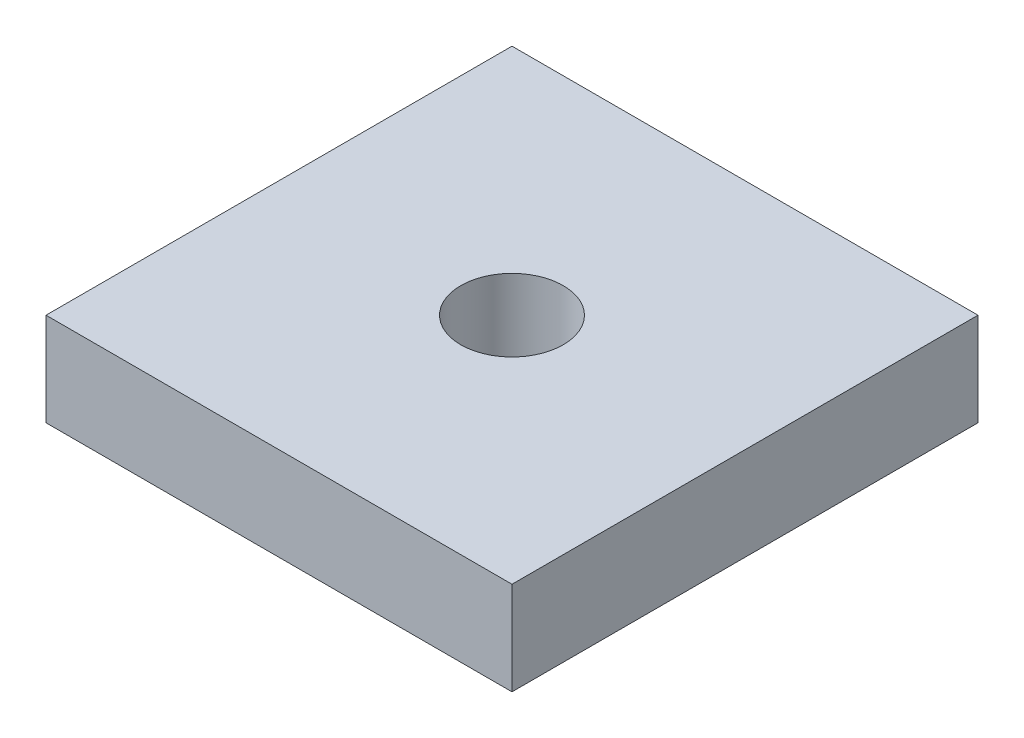
from build123d import *

# Parameters (mm, degrees)
SKETCH_1_W             = 15
SKETCH_1_H             = 3
EXTRUDE_1_DEPTH        = 15
HOLE_WIZARD_M4_1_D     = 3.3
HOLE_WIZARD_M4_1_DEPTH = 11.5
HOLE_WIZARD_M4_1_TIP   = 0.991420021


with BuildPart() as part:
    # 草图1 → 凸台-拉伸1 (new body)
    with BuildSketch(Plane.ZY):
        with Locations((-2173.305231444, -786.615322881)):
            Rectangle(SKETCH_1_W, SKETCH_1_H)
    extrude(amount=EXTRUDE_1_DEPTH)

    # M4 螺纹孔1
    with Locations(Plane(origin=(0, -785.115322881, 0), x_dir=(-1, 0, 0), z_dir=(0, 1, 0))):
        with Locations((7.5, -2173.305231444)):
            Hole(HOLE_WIZARD_M4_1_D / 2, depth=HOLE_WIZARD_M4_1_DEPTH)
            with Locations((0, 0, -(HOLE_WIZARD_M4_1_DEPTH + HOLE_WIZARD_M4_1_TIP / 2))):  # 118° drill point
                Cone(0, HOLE_WIZARD_M4_1_D / 2, HOLE_WIZARD_M4_1_TIP, mode=Mode.SUBTRACT)


solid = part.part
